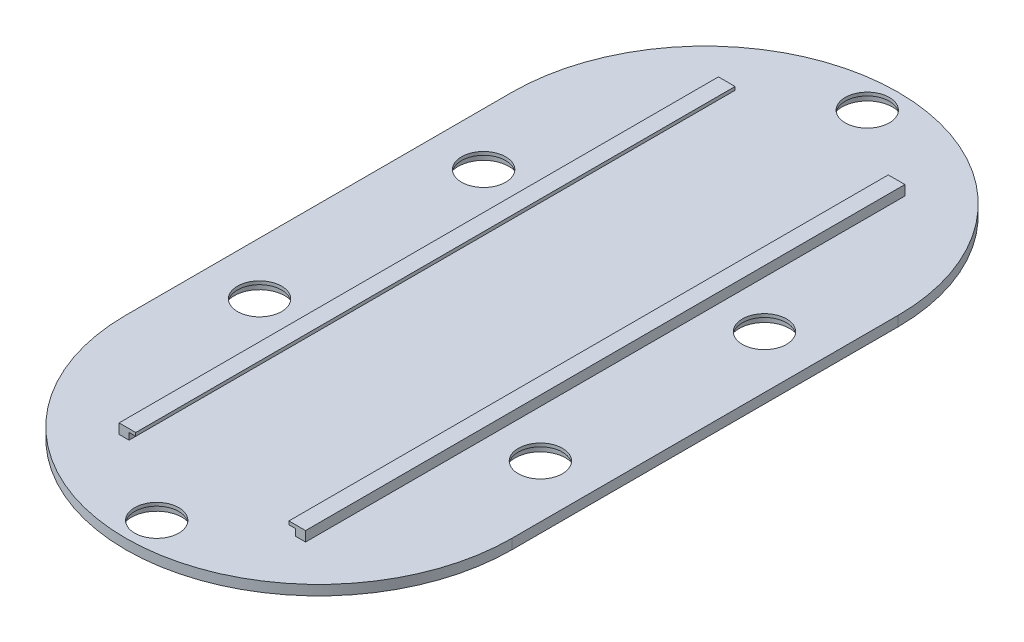
from build123d import *

# Parameters (mm, degrees)
SKETCH1_R           = 6.625
BOSS_EXTRUDE1_DEPTH = 3
SKETCH2_R           = 7.6
CUT_EXTRUDE1_DEPTH  = 2
BOSS_EXTRUDE2_DEPTH = 90


with BuildPart() as part:
    # Sketch1 → Boss-Extrude1 (new body)
    with BuildSketch(Plane(origin=(0, 0, 0), x_dir=(1, 0, 0), z_dir=(0, 1, 0))):
        with BuildLine():
            Line((58, -58), (58, 58))
            ThreePointArc((58, 58), (0, 116), (-58, 58))
            Line((-58, 58), (-58, -58))
            ThreePointArc((-58, -58), (0, -116), (58, -58))
        make_face()
        with Locations((0, 106.699495206)):
            Circle(SKETCH1_R, mode=Mode.SUBTRACT)
        with Locations((42.175, 33.650252397)):
            Circle(SKETCH1_R, mode=Mode.SUBTRACT)
        with Locations((-42.175, 33.650252397)):
            Circle(SKETCH1_R, mode=Mode.SUBTRACT)
        with Locations((-42.175, -33.650252397)):
            Circle(SKETCH1_R, mode=Mode.SUBTRACT)
        with Locations((0, -106.699495206)):
            Circle(SKETCH1_R, mode=Mode.SUBTRACT)
        with Locations((42.175, -33.650252397)):
            Circle(SKETCH1_R, mode=Mode.SUBTRACT)
    extrude(amount=BOSS_EXTRUDE1_DEPTH)

    # Sketch2 → Cut-Extrude1 (cut)
    with BuildSketch(Plane.XZ):
        with Locations((42.175, -33.650252397)):
            Circle(SKETCH2_R)
        with Locations((-42.175, -33.650252397)):
            Circle(SKETCH2_R)
        with Locations((0, -106.699495206)):
            Circle(SKETCH2_R)
        with Locations((42.175, 33.650252397)):
            Circle(SKETCH2_R)
        with Locations((0, 106.699495206)):
            Circle(SKETCH2_R)
        with Locations((-42.175, 33.650252397)):
            Circle(SKETCH2_R)
    extrude(amount=-CUT_EXTRUDE1_DEPTH, mode=Mode.SUBTRACT)

    # Sketch3 → Boss-Extrude2 (add, symmetric)
    with BuildSketch(Plane.XY):
        Polygon((-23, 5), (-25, 5), (-25, 3), (-28, 3), (-28, 6), (-23, 6), align=None)
        Polygon((28, 3), (28, 6), (23, 6), (23, 5), (25, 5), (25, 3), align=None)
    extrude(amount=BOSS_EXTRUDE2_DEPTH, both=True)


solid = part.part
